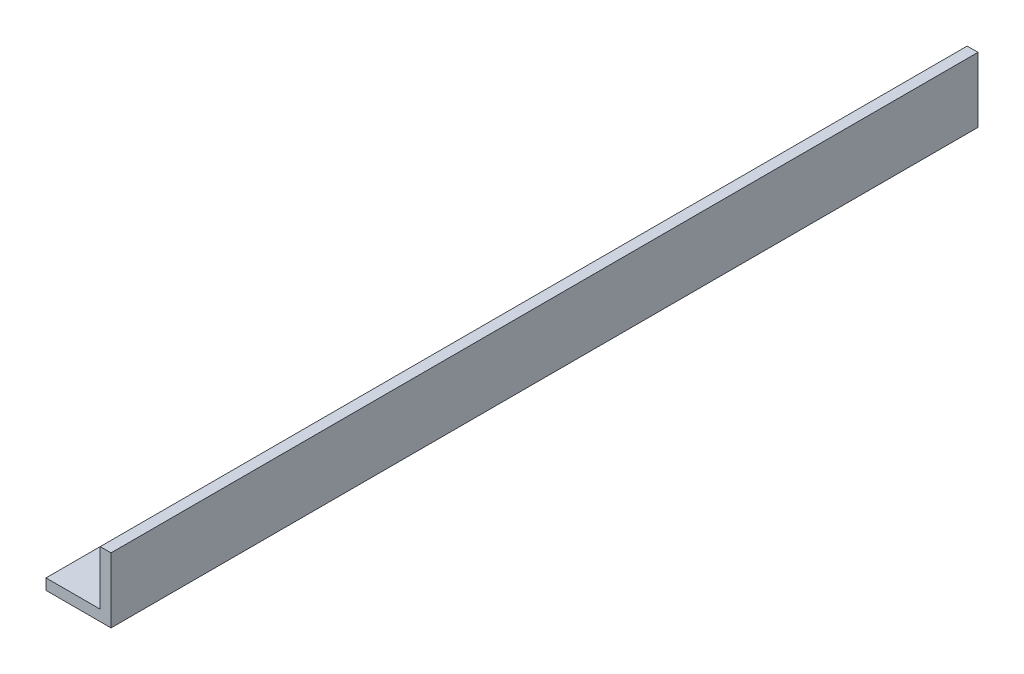
from build123d import *

# Parameters (mm, degrees)
BOSS_EXTRUDE1_DEPTH = 63.5


with BuildPart() as part:
    # Sketch3 → Boss-Extrude1 (new body, symmetric)
    with BuildSketch(Plane.XY):
        Polygon((3.175, -3.175), (-4.7625, -3.175), (-4.7625, -4.7625), (4.7625, -4.7625), (4.7625, 4.7625), (3.175, 4.7625), align=None)
    extrude(amount=BOSS_EXTRUDE1_DEPTH, both=True)


solid = part.part
